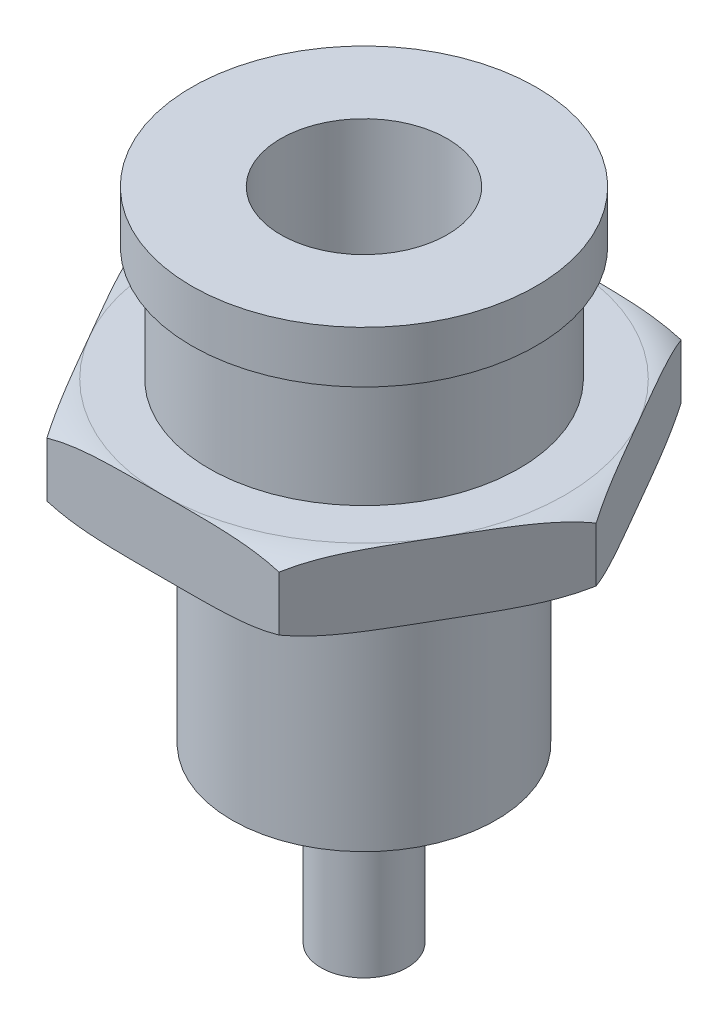
from build123d import *

# Parameters (mm, degrees)
BOSS_EXTRUDE1_START = 4
BOSS_EXTRUDE1_DEPTH = 2.5


with BuildPart() as part:
    # Sketch1 → Revolve1 (revolve)
    with BuildSketch(Plane.XY):
        Polygon((0, 0), (0, 12.8), (2.9, 12.8), (2.9, 22.8), (6, 22.8), (6, 21), (5.4, 21), (5.4, 16), (4.6, 16), (4.6, 6), (1.5, 6), (1.5, 0), align=None)
    revolve(axis=Axis((0, 0, 0), (0, 1, 0)))

    # Sketch2 → Boss-Extrude1 (add)
    with BuildSketch(Plane.XZ.offset(-21).offset(BOSS_EXTRUDE1_START)):
        Polygon((8.082903769, 0), (4.041451884, 7), (-4.041451884, 7), (-8.082903769, 0), (-4.041451884, -7), (4.041451884, -7), align=None)
    extrude(amount=BOSS_EXTRUDE1_DEPTH)

    # Sketch3 → Cut-Revolve1 (revolve, cut)
    with BuildSketch(Plane.XY):
        with BuildLine():
            Line((-8.082903769, 16.7), (-8.082903769, 17))
            Line((-8.082903769, 17), (-7, 17))
            ThreePointArc((-7, 17), (-7.561845302, 16.923613695), (-8.082903769, 16.7))
        make_face()
        with BuildLine():
            Line((-8.082903769, 14.8), (-8.082903769, 14.5))
            Line((-8.082903769, 14.5), (-7, 14.5))
            ThreePointArc((-7, 14.5), (-7.561845302, 14.576386305), (-8.082903769, 14.8))
        make_face()
    revolve(axis=Axis((0, 14.5, 0), (0, 1, 0)), mode=Mode.SUBTRACT)


solid = part.part
